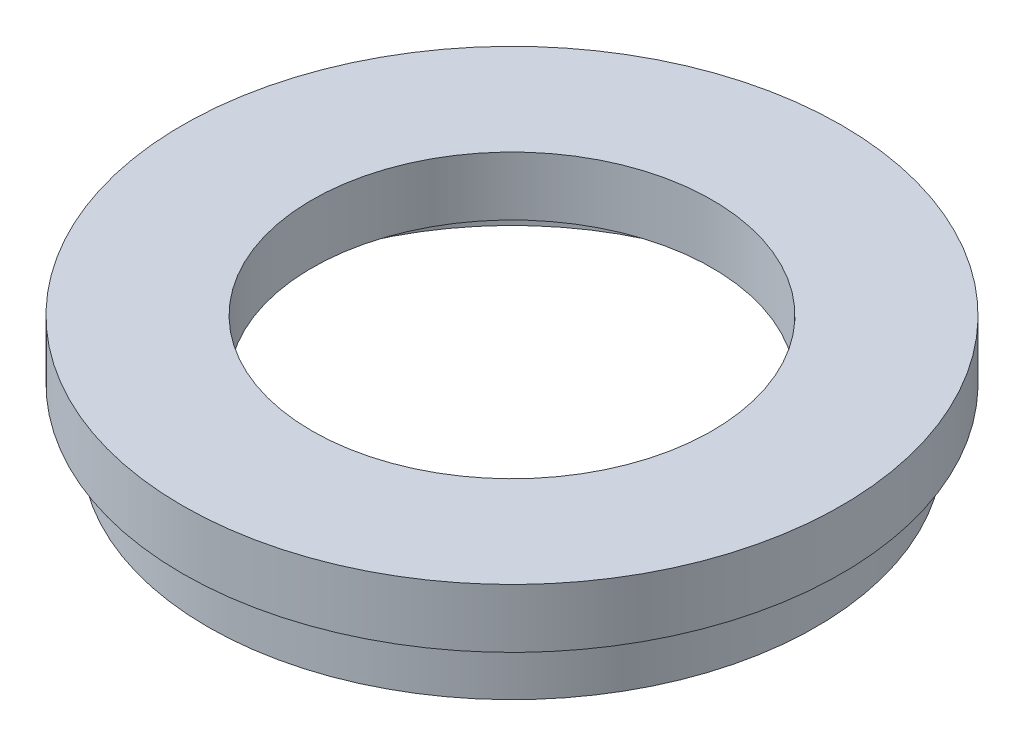
from build123d import *


with BuildPart() as part:
    # 草图1 → 旋转1 (revolve)
    with BuildSketch(Plane.XY, mode=Mode.PRIVATE) as revolve_1_sk:
        Polygon((25.845, 0), (23.5, 0), (23.5, 4), (24.1, 4), (24.1, 5), (17, 5), (17, 10), (28, 10), (28, 5), (25.45, 5), (25.45, 4), (25.845, 4), align=None)
    revolve(revolve_1_sk.sketch.rotate(Axis((0, 13.744680851, 0), (0, -1, 0)), 90), axis=Axis((0, 13.744680851, 0), (0, -1, 0)))  # turned: the seam where the file's is


solid = part.part
